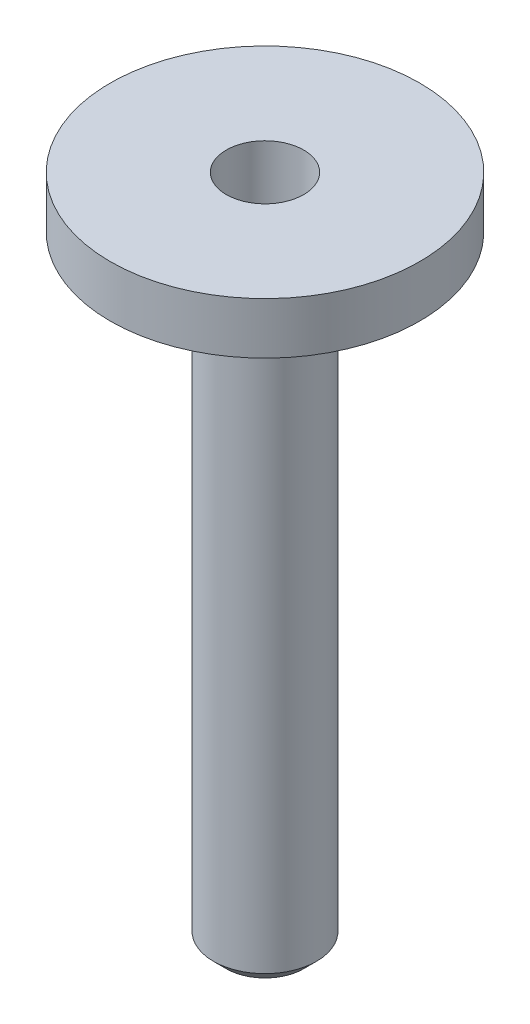
from build123d import *

# Parameters (mm, degrees)
F_3_8_0_375_DIAMETER_HOLE1_D     = 9.525
F_3_8_0_375_DIAMETER_HOLE1_DEPTH = 77.7875
F_3_8_0_375_DIAMETER_HOLE1_TIP   = 2.861598698
CHAMFER1_SIZE                    = 1.5875


with BuildPart() as part:
    # Sketch1 → Revolve1 (revolve)
    with BuildSketch(Plane.XY):
        Polygon((0, 0), (-19.05, 0), (-19.05, -6.35), (-17.4625, -6.35), (-17.4625, -3.81), (-14.1605, -3.81), (-14.1605, -6.35), (-6.35, -6.35), (-6.35, -82.55), (0, -82.55), align=None)
    revolve(axis=Axis((0, -82.55, 0), (0, 1, 0)))

    # 3/8 (0.375) Diameter Hole1
    with Locations(Plane(origin=(0, 0, 0), x_dir=(1, 0, 0), z_dir=(0, 1, 0))):
        with Locations((0, 0)):
            Hole(F_3_8_0_375_DIAMETER_HOLE1_D / 2, depth=F_3_8_0_375_DIAMETER_HOLE1_DEPTH)
            with Locations((0, 0, -(F_3_8_0_375_DIAMETER_HOLE1_DEPTH + F_3_8_0_375_DIAMETER_HOLE1_TIP / 2))):  # 118° drill point
                Cone(0, F_3_8_0_375_DIAMETER_HOLE1_D / 2, F_3_8_0_375_DIAMETER_HOLE1_TIP, mode=Mode.SUBTRACT)

    # Chamfer1
    chamfer1_edges = [part.edges().sort_by_distance(p)[0] for p in [
        (6.35, -82.55, 0),
    ]]
    chamfer(chamfer1_edges, length=CHAMFER1_SIZE)


solid = part.part
